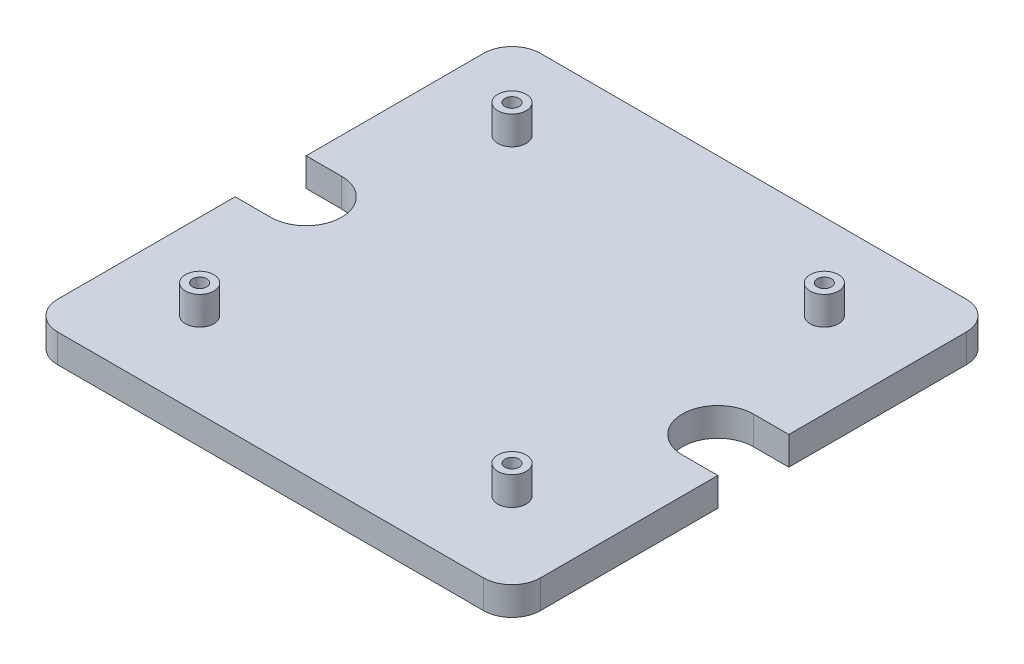
from build123d import *

# Parameters (mm, degrees)
SKETCH2_W           = 170
SKETCH2_H           = 170
BOSS_EXTRUDE1_DEPTH = 10
SKETCH1_R           = 5
SKETCH1_R_2         = 2.5
BOSS_EXTRUDE2_DEPTH = 20
FILLET1_R           = 10
SKETCH3_R           = 5
CUT_EXTRUDE1_DEPTH  = 6.5
CUT_EXTRUDE2_DEPTH  = 11


with BuildPart() as part:
    # Sketch2 → Boss-Extrude1 (new body)
    with BuildSketch(Plane(origin=(0, 0, 0), x_dir=(1, 0, 0), z_dir=(0, 1, 0))):
        with Locations((85, 85)):
            Rectangle(SKETCH2_W, SKETCH2_H)
    extrude(amount=BOSS_EXTRUDE1_DEPTH)

    # Sketch1 → Boss-Extrude2 (add)
    with BuildSketch(Plane(origin=(0, 0, 0), x_dir=(1, 0, 0), z_dir=(0, 1, 0))):
        with Locations((30, 30)):
            Circle(SKETCH1_R)
        with Locations((30, 30)):
            Circle(SKETCH1_R_2, mode=Mode.SUBTRACT)
        with Locations((140, 30)):
            Circle(SKETCH1_R)
        with Locations((140, 30)):
            Circle(SKETCH1_R_2, mode=Mode.SUBTRACT)
        with Locations((30, 140)):
            Circle(SKETCH1_R)
        with Locations((30, 140)):
            Circle(SKETCH1_R_2, mode=Mode.SUBTRACT)
        with Locations((140, 140)):
            Circle(SKETCH1_R)
        with Locations((140, 140)):
            Circle(SKETCH1_R_2, mode=Mode.SUBTRACT)
    extrude(amount=BOSS_EXTRUDE2_DEPTH)

    # Fillet1
    fillet1_edges = [part.edges().sort_by_distance(p)[0] for p in [
        (0, 5, -170),
        (170, 5, -170),
        (170, 5, 0),
        (0, 5, 0),
    ]]
    fillet(fillet1_edges, radius=FILLET1_R)

    # Sketch3 → Cut-Extrude1 (cut)
    with BuildSketch(Plane(origin=(0, 0, 0), x_dir=(-1, 0, 0), z_dir=(0, -1, 0))):
        with Locations((-30.625, 135)):
            Circle(SKETCH3_R)
        with Locations((-139.375, 135)):
            Circle(SKETCH3_R)
        with Locations((-139.375, 35)):
            Circle(SKETCH3_R)
        with Locations((-30.625, 35)):
            Circle(SKETCH3_R)
    extrude(amount=-CUT_EXTRUDE1_DEPTH, mode=Mode.SUBTRACT)

    # Sketch4 → Cut-Extrude2 (cut, through all)
    with BuildSketch(Plane(origin=(0, 10, 0), x_dir=(1, 0, 0), z_dir=(0, 1, 0))):
        with BuildLine():
            ThreePointArc((25, 85), (21.338834765, 93.838834765), (12.5, 97.5))
            Line((12.5, 97.5), (0, 97.5))
            Line((0, 97.5), (0, 72.5))
            Line((0, 72.5), (12.5, 72.5))
            ThreePointArc((12.5, 72.5), (21.338834765, 76.161165235), (25, 85))
        make_face()
        with BuildLine():
            ThreePointArc((157.5, 97.5), (145, 85), (157.5, 72.5))
            Line((157.5, 72.5), (170, 72.5))
            Line((170, 72.5), (170, 97.5))
            Line((170, 97.5), (157.5, 97.5))
        make_face()
    extrude(amount=-CUT_EXTRUDE2_DEPTH, mode=Mode.SUBTRACT)


solid = part.part
